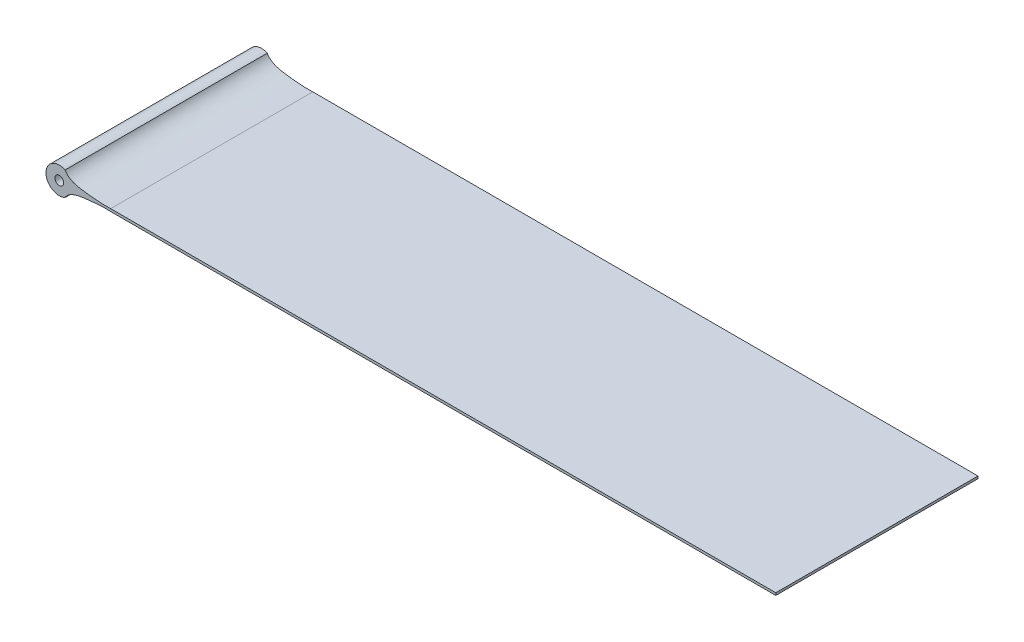
from build123d import *

# Parameters (mm, degrees)
BOSS_EXTRU_1_DEPTH      = 11.4
BOSS_EXTRU_1_DEPTH_BACK = 11.4
ESQUISSE2_R             = 0.5


with BuildPart() as part:
    # Esquisse2 → Boss.-Extru.1 (new, two sides: drawn at the far end of the back side and taken through both)
    with BuildSketch(Plane.XY.offset(-BOSS_EXTRU_1_DEPTH_BACK)):
        with BuildLine():
            Line((5.791060422, 0.142064292), (80.791060422, 0.133235508))
            ThreePointArc((80.791060422, 0.133235508), (80.791208073, 0), (80.791060422, -0.133235508))
            Line((80.791060422, -0.133235508), (5.791060422, -0.142064292))
            add(Edge.make_bspline(
                [(0.650938463, -1.351398948), (1.114517622, -0.510365175), (3.069897688, -0.268204079), (5.029284194, -0.087299538), (5.791060422, -0.142064292)],
                knots=[0, 0, 0, 0, 0.614720571, 1, 1, 1, 1], degree=3))
            ThreePointArc((0.650938463, -1.351398948), (-1.5, 0), (0.650938463, 1.351398948))
            add(Edge.make_bspline(
                [(0.650938463, 1.351398948), (1.114517622, 0.510365175), (3.069897688, 0.268204079), (5.029284194, 0.087299538), (5.791060422, 0.142064292)],
                knots=[0, 0, 0, 0, 0.614720571, 1, 1, 1, 1], degree=3))
        make_face()
        Circle(ESQUISSE2_R, mode=Mode.SUBTRACT)
    extrude(amount=BOSS_EXTRU_1_DEPTH + BOSS_EXTRU_1_DEPTH_BACK)


solid = part.part
